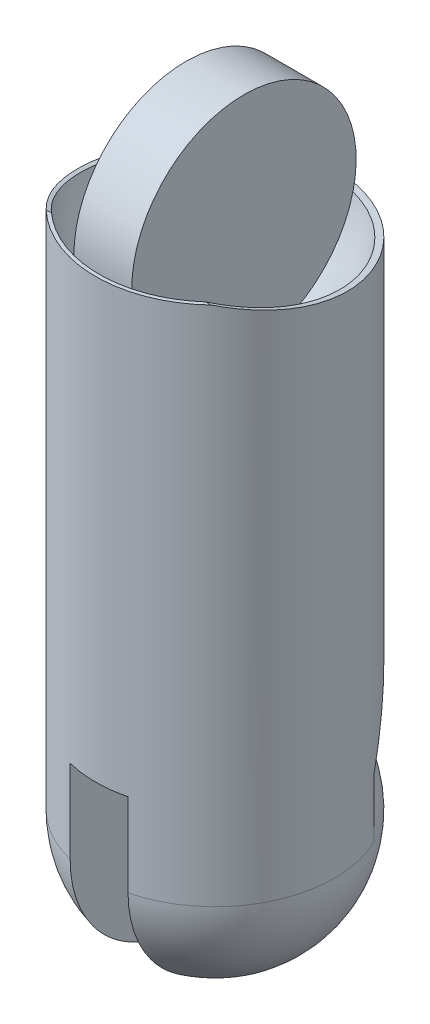
from build123d import *

# Parameters (mm, degrees)
CROQUIS1_R              = 8.25
SALIENTE_EXTRUIR1_DEPTH = 36
CORTAR_EXTRUIR5_DEPTH   = 18
CORTAR_EXTRUIR7_DEPTH   = 15
CROQUIS23_R             = 7.75
SALIENTE_EXTRUIR4_DEPTH = 2
CROQUIS25_W             = 4
CROQUIS25_H             = 14
CORTAR_EXTRUIR8_DEPTH   = 15


with BuildPart() as part:
    # Croquis1 → Saliente-Extruir1 (new body)
    with BuildSketch(Plane(origin=(0, 0, 0), x_dir=(1, 0, 0), z_dir=(0, 1, 0))):
        Circle(CROQUIS1_R)
    extrude(amount=SALIENTE_EXTRUIR1_DEPTH)

    # Croquis3 → Cortar-Extruir5 (cut, symmetric)
    with BuildSketch(Plane(origin=(0, 0, 0), x_dir=(0, 0, -1), z_dir=(1, 0, 0))):
        Polygon((8.25, 0), (8.25, 14), (3.5, 4), (3.5, 0), align=None)
    extrude(amount=CORTAR_EXTRUIR5_DEPTH, both=True, mode=Mode.SUBTRACT)

    # Croquis18 → Revolución1 (revolve)
    with BuildSketch(Plane(origin=(0, 0, 0), x_dir=(0, 0, -1), z_dir=(1, 0, 0))):
        with BuildLine():
            Line((0, 8.25), (0, -8.25))
            ThreePointArc((0, -8.25), (8.25, 0), (0, 8.25))
        make_face()
    revolve(axis=Axis((0, 8.25, 0), (0, -1, 0)))

    # Croquis20 → Cortar-Revolución1 (revolve, cut)
    with BuildSketch(Plane(origin=(0, 36, 0), x_dir=(1, 0, 0), z_dir=(0, 1, 0))):
        with BuildLine():
            Line((-8, 0), (8, 0))
            ThreePointArc((8, 0), (0, 8), (-8, 0))
        make_face()
    revolve(axis=Axis((-8, 36, 0), (1, 0, 0)), mode=Mode.SUBTRACT)

    # Croquis24 → Cortar-Extruir7 (cut, symmetric)
    with BuildSketch(Plane(origin=(0, 0, 0), x_dir=(0, 0, -1), z_dir=(1, 0, 0))):
        with BuildLine():
            Line((-5.973353696, 36), (8.25, 36))
            Line((8.25, 36), (8.25, 34.163037065))
            add(Edge.make_bspline(
                [(-5.973353696, 36), (-1.37807863, 34.604512728), (3.281869782, 34.274988011), (8.25, 34.163037065)],
                knots=[0, 0, 0, 0, 1, 1, 1, 1], degree=3))
        make_face()
    extrude(amount=CORTAR_EXTRUIR7_DEPTH, both=True, mode=Mode.SUBTRACT)

    # Croquis23 → Saliente-Extruir4 (add, symmetric)
    with BuildSketch(Plane(origin=(0, 0, 0), x_dir=(0, 0, -1), z_dir=(1, 0, 0))):
        with Locations((0, 36)):
            Circle(CROQUIS23_R)
    extrude(amount=SALIENTE_EXTRUIR4_DEPTH, both=True)

    # Croquis25 → Cortar-Extruir8 (cut, symmetric)
    with BuildSketch(Plane.XY):
        with Locations((0, -1.25)):
            Rectangle(CROQUIS25_W, CROQUIS25_H)
    extrude(amount=CORTAR_EXTRUIR8_DEPTH, both=True, mode=Mode.SUBTRACT)


solid = part.part
